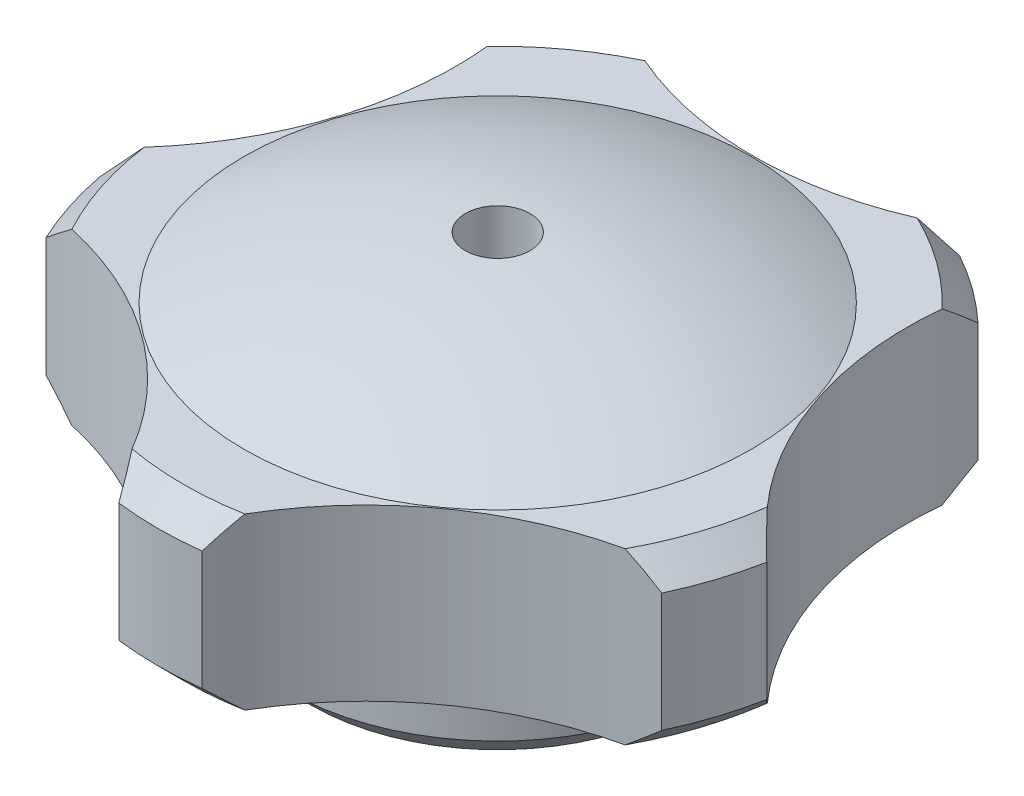
from build123d import *

# Parameters (mm, degrees)
CHANFREIN1_SIZE              = 0.3
ESQUISSE2_R                  = 4
ENL_V_MAT_EXTRU_1_DEPTH      = 2
R_P_TITION_CIRCULAIRE1_COUNT = 5


with BuildPart() as part:
    # Esquisse1 → Révolution1 (revolve)
    with BuildSketch(Plane.XY):
        with BuildLine():
            Line((-0.38, 0), (-2.5, 0))
            Line((-2.5, 0), (-2.5, 1))
            Line((-2.5, 1), (-4, 1))
            Line((-4, 1), (-4, 3))
            Line((-4, 3), (-2.985871259, 3))
            ThreePointArc((-2.985871259, 3), (-1.71951066, 3.492907341), (-0.38, 3.721682356))
            Line((-0.38, 3.721682356), (-0.38, 3))
            Line((-0.38, 3), (-0.38, 0))
        make_face()
    revolve(axis=Axis((0, 0, 0), (0, 1, 0)))

    # Chanfrein1
    chanfrein1_edges = [part.edges().sort_by_distance(p)[0] for p in [
        (2.5, 0, 0),
        (4, 3, 0),
        (4, 1, 0),
    ]]
    chamfer(chanfrein1_edges, length=CHANFREIN1_SIZE)

    # Esquisse2 → Enlèv. mat.-Extru.1 (cut)
    with BuildSketch(Plane(origin=(0, 3, 0), x_dir=(1, 0, 0), z_dir=(0, 1, 0))):
        with Locations((0, 7)):
            Circle(ESQUISSE2_R)
    enl_v_mat_extru_1 = extrude(amount=-ENL_V_MAT_EXTRU_1_DEPTH, mode=Mode.SUBTRACT)

    # Répétition circulaire1: Enlèv. mat.-Extru.1 ×5 about axis
    r_p_tition_circulaire1_axis = Axis((0, 0, 0), (0, 1, 0))
    for i in range(1, R_P_TITION_CIRCULAIRE1_COUNT):
        add(enl_v_mat_extru_1.rotate(r_p_tition_circulaire1_axis, i * 360 / R_P_TITION_CIRCULAIRE1_COUNT), mode=Mode.SUBTRACT)


solid = part.part
